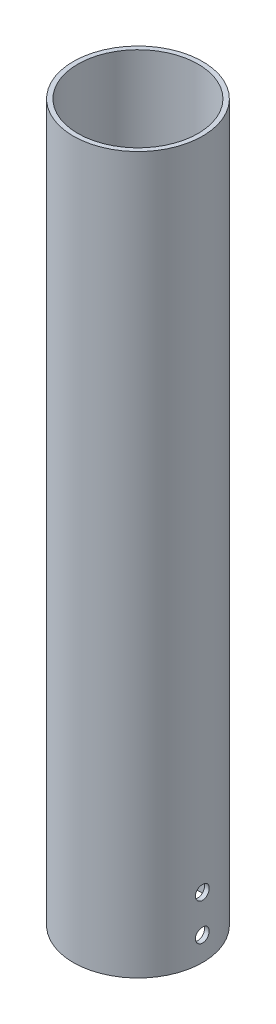
from build123d import *

# Parameters (mm, degrees)
SKETCH1_R               = 27.1
SKETCH1_R_2             = 25.2
BOSS_EXTRUDE1_DEPTH     = 300
SKETCH2_R               = 2.9
CUT_EXTRUDE1_DEPTH      = 28.1
CUT_EXTRUDE1_DEPTH_BACK = 28.1


with BuildPart() as part:
    # Sketch1 → Boss-Extrude1 (new body)
    with BuildSketch(Plane(origin=(0, 0, 0), x_dir=(1, 0, 0), z_dir=(0, 1, 0))):
        Circle(SKETCH1_R)
        Circle(SKETCH1_R_2, mode=Mode.SUBTRACT)
    extrude(amount=BOSS_EXTRUDE1_DEPTH)

    # Sketch2 → Cut-Extrude1 (cut, two sides)
    with BuildSketch(Plane(origin=(0, 0, 0), x_dir=(0, 0, -1), z_dir=(1, 0, 0))) as cut_extrude1_sk:
        with Locations((0, 10)):
            Circle(SKETCH2_R)
        with Locations((0, 25.5)):
            Circle(SKETCH2_R)
    extrude(amount=CUT_EXTRUDE1_DEPTH, mode=Mode.SUBTRACT)
    extrude(cut_extrude1_sk.sketch, amount=-CUT_EXTRUDE1_DEPTH_BACK, mode=Mode.SUBTRACT)


solid = part.part
